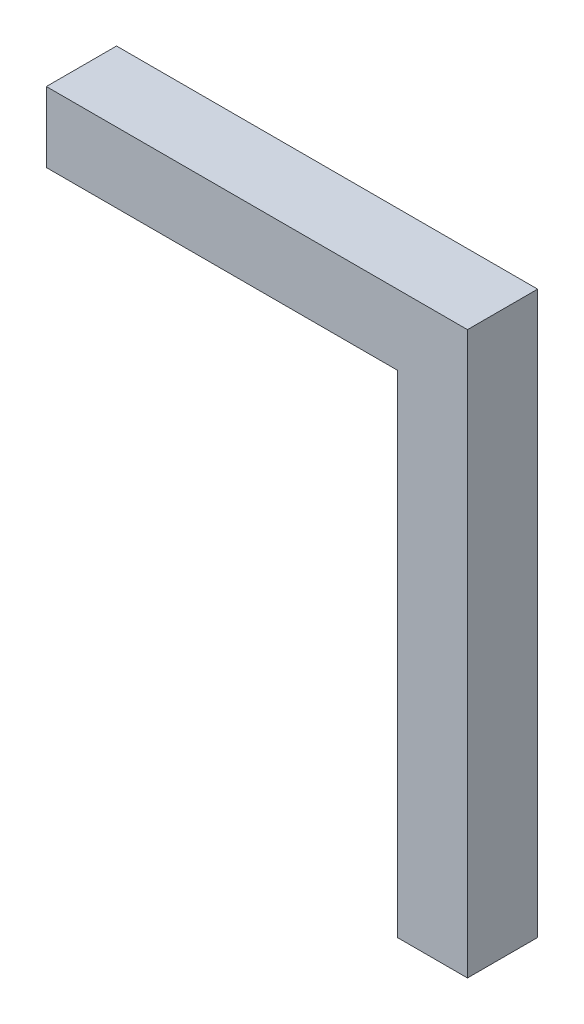
from build123d import *

# Parameters (mm, degrees)
BOSS_EXTRUDE1_DEPTH = 0.5


with BuildPart() as part:
    # Sketch1 → Boss-Extrude1 (new body)
    with BuildSketch(Plane.XY):
        Polygon((-5.7, 13.56264653), (-5.7, 17.06264653), (-8.2, 17.06264653), (-8.2, 17.56264653), (-5.2, 17.56264653), (-5.2, 13.56264653), align=None)
    extrude(amount=BOSS_EXTRUDE1_DEPTH)


solid = part.part
